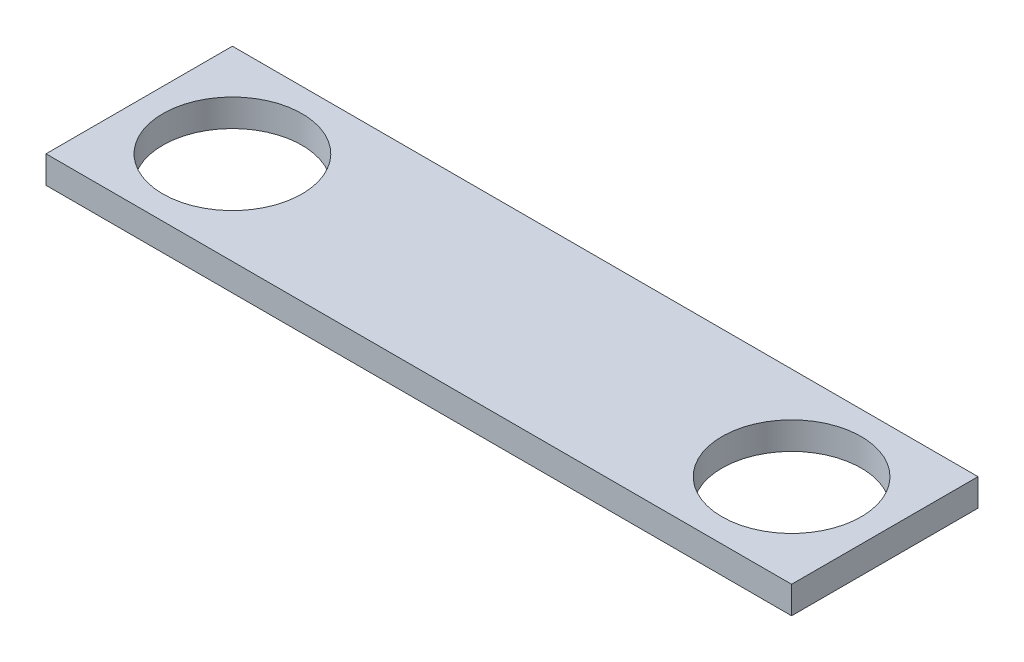
from build123d import *

# Parameters (mm, degrees)
SKETCH1_W           = 152.4
SKETCH1_H           = 38.1
BOSS_EXTRUDE1_DEPTH = 5.588
SKETCH6_R           = 14.224
CUT_EXTRUDE4_DEPTH  = 6.588
SKETCH7_R           = 14.224
CUT_EXTRUDE5_DEPTH  = 6.588


with BuildPart() as part:
    # Sketch1 → Boss-Extrude1 (new body)
    with BuildSketch(Plane(origin=(0, 0, 0), x_dir=(1, 0, 0), z_dir=(0, 1, 0))):
        with Locations((76.2, 19.05)):
            Rectangle(SKETCH1_W, SKETCH1_H)
    extrude(amount=BOSS_EXTRUDE1_DEPTH)

    # Sketch6 → Cut-Extrude4 (cut, through all)
    with BuildSketch(Plane(origin=(0, 5.588, 0), x_dir=(1, 0, 0), z_dir=(0, 1, 0))):
        with Locations((19.05, 19.05)):
            Circle(SKETCH6_R)
    extrude(amount=-CUT_EXTRUDE4_DEPTH, mode=Mode.SUBTRACT)

    # Sketch7 → Cut-Extrude5 (cut, through all)
    with BuildSketch(Plane(origin=(0, 5.588, 0), x_dir=(1, 0, 0), z_dir=(0, 1, 0))):
        with Locations((133.35, 19.05)):
            Circle(SKETCH7_R)
    extrude(amount=-CUT_EXTRUDE5_DEPTH, mode=Mode.SUBTRACT)


solid = part.part
